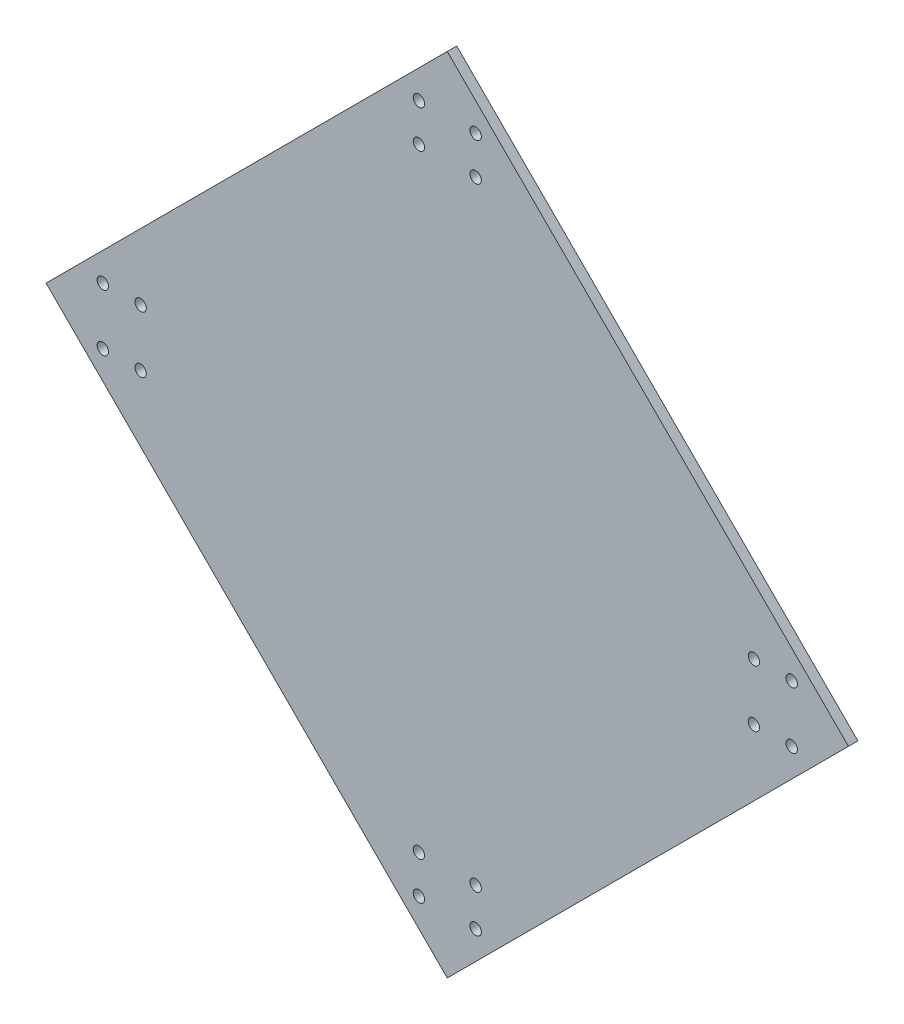
from build123d import *

# Parameters (mm, degrees)
SKETCH2_R           = 1.5
BOSS_EXTRUDE1_DEPTH = 2.5


with BuildPart() as part:
    # Sketch2 → Boss-Extrude1 (new body)
    with BuildSketch(Plane.XY):
        Polygon((0, 0), (106.066017178, 106.066017178), (0, 212.132034356), (-106.066017178, 106.066017178), align=None)
        with Locations((-7.5, 197.132034356)):
            Circle(SKETCH2_R, mode=Mode.SUBTRACT)
        with Locations((7.5, 197.132034356)):
            Circle(SKETCH2_R, mode=Mode.SUBTRACT)
        with Locations((-7.5, 187.132034356)):
            Circle(SKETCH2_R, mode=Mode.SUBTRACT)
        with Locations((7.5, 187.132034356)):
            Circle(SKETCH2_R, mode=Mode.SUBTRACT)
        with Locations((81.066019356, 113.566015)):
            Circle(SKETCH2_R, mode=Mode.SUBTRACT)
        with Locations((81.066019356, 98.566015)):
            Circle(SKETCH2_R, mode=Mode.SUBTRACT)
        with Locations((91.066019356, 98.566015)):
            Circle(SKETCH2_R, mode=Mode.SUBTRACT)
        with Locations((91.066019356, 113.566015)):
            Circle(SKETCH2_R, mode=Mode.SUBTRACT)
        with Locations((7.5, 24.999995644)):
            Circle(SKETCH2_R, mode=Mode.SUBTRACT)
        with Locations((-7.5, 24.999995644)):
            Circle(SKETCH2_R, mode=Mode.SUBTRACT)
        with Locations((-7.5, 14.999995644)):
            Circle(SKETCH2_R, mode=Mode.SUBTRACT)
        with Locations((7.5, 14.999995644)):
            Circle(SKETCH2_R, mode=Mode.SUBTRACT)
        with Locations((-81.066019356, 98.566015)):
            Circle(SKETCH2_R, mode=Mode.SUBTRACT)
        with Locations((-81.066019356, 113.566015)):
            Circle(SKETCH2_R, mode=Mode.SUBTRACT)
        with Locations((-91.066019356, 113.566015)):
            Circle(SKETCH2_R, mode=Mode.SUBTRACT)
        with Locations((-91.066019356, 98.566015)):
            Circle(SKETCH2_R, mode=Mode.SUBTRACT)
    extrude(amount=BOSS_EXTRUDE1_DEPTH)


solid = part.part
